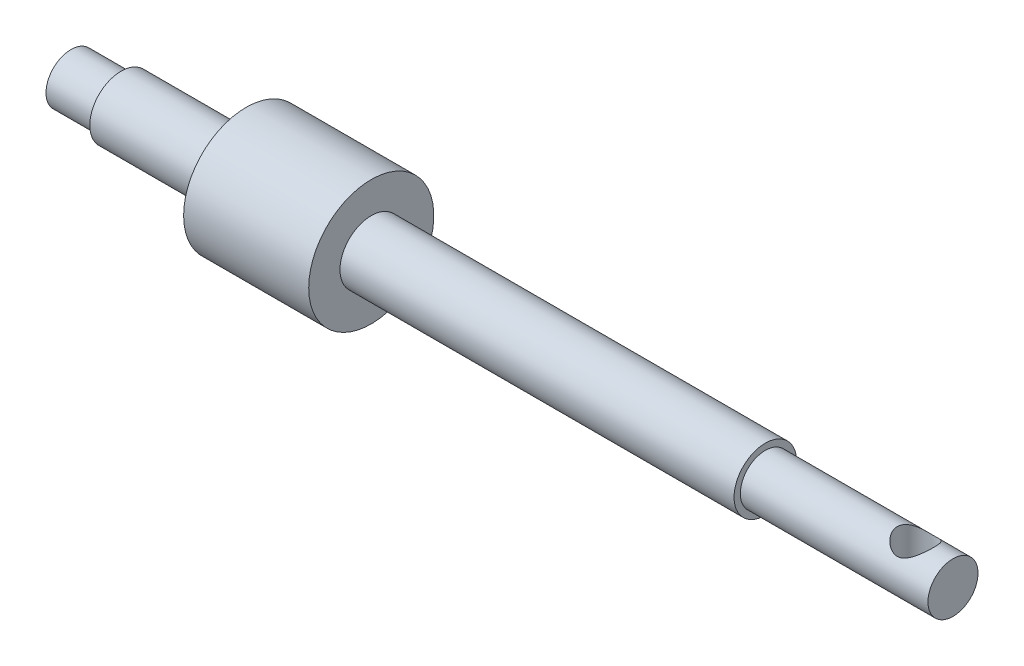
from build123d import *

# Parameters (mm, degrees)
SKETCH_2_R          = 2
EXTRUDE_1_DEPTH     = 2
SKETCH_5_R          = 1.45
CUT_EXTRUDE_4_DEPTH = 5


with BuildPart() as part:
    # 草图1 → 旋转1 (revolve)
    with BuildSketch(Plane.XY):
        Polygon((-52.479220812, 2.5), (-52.479220812, 2), (-56.479220812, 2), (-56.479220812, 0), (12.020779188, 0), (12.020779188, 2), (-0.979220812, 2), (-0.979220812, 2.5), (-32.479220812, 2.5), (-32.479220812, 5), (-42.479220812, 5), (-42.479220812, 2.5), align=None)
    revolve(axis=Axis((-56.479220812, 0, 0), (1, 0, 0)))

    # 草图2 → 凸台-拉伸1 (add)
    with BuildSketch(Plane(origin=(12.020779188, 0, 0), x_dir=(0, 0, -1), z_dir=(1, 0, 0))):
        Circle(SKETCH_2_R)
    extrude(amount=EXTRUDE_1_DEPTH)

    # 草图5 → 切除-拉伸4 (cut, symmetric)
    with BuildSketch(Plane(origin=(0, 0, 0), x_dir=(1, 0, 0), z_dir=(0, 1, 0))):
        with Locations((11.020779188, 0)):
            Circle(SKETCH_5_R)
    extrude(amount=CUT_EXTRUDE_4_DEPTH, both=True, mode=Mode.SUBTRACT)


solid = part.part
